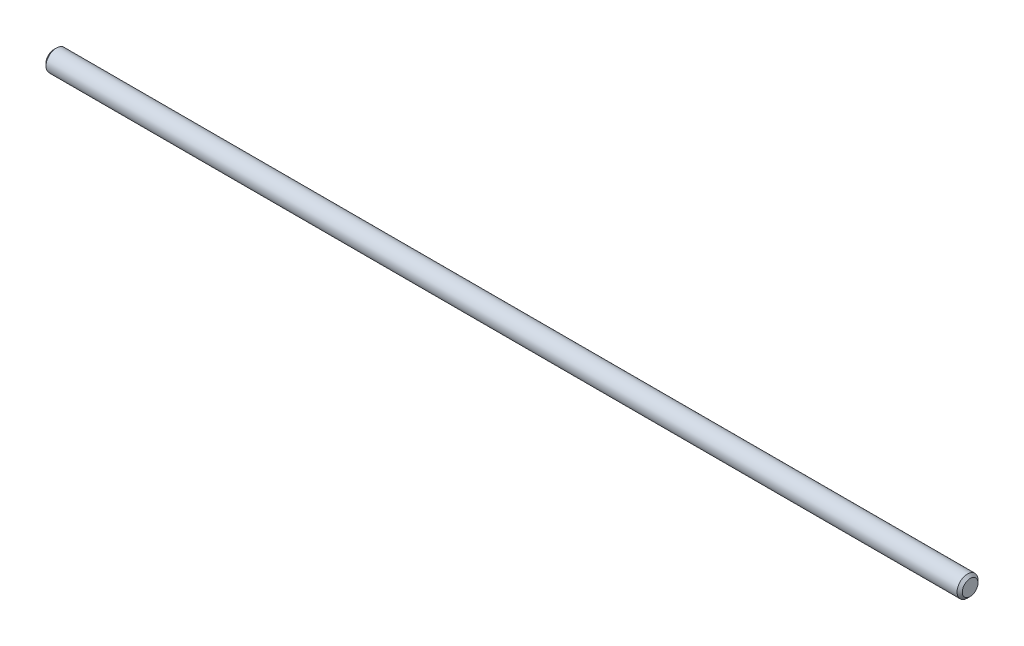
from build123d import *

# Parameters (mm, degrees)
SALIENTE_EXTRUIR1_DEPTH      = 175
SALIENTE_EXTRUIR1_DEPTH_BACK = 175
CROQUIS1_R                   = 4
CHAFL_N1_SIZE                = 1


with BuildPart() as part:
    # Croquis1 → Saliente-Extruir1 (new, two sides: drawn at the far end of the back side and taken through both)
    with BuildSketch(Plane(origin=(0, 0, 0), x_dir=(0, 0, -1), z_dir=(1, 0, 0)).offset(-SALIENTE_EXTRUIR1_DEPTH_BACK)):
        Circle(CROQUIS1_R)
    extrude(amount=SALIENTE_EXTRUIR1_DEPTH + SALIENTE_EXTRUIR1_DEPTH_BACK)

    # Chaflán1
    chafl_n1_edges = [part.edges().sort_by_distance(p)[0] for p in [
        (-175, 0, 4),
        (175, 0, 4),
    ]]
    chamfer(chafl_n1_edges, length=CHAFL_N1_SIZE)


solid = part.part
